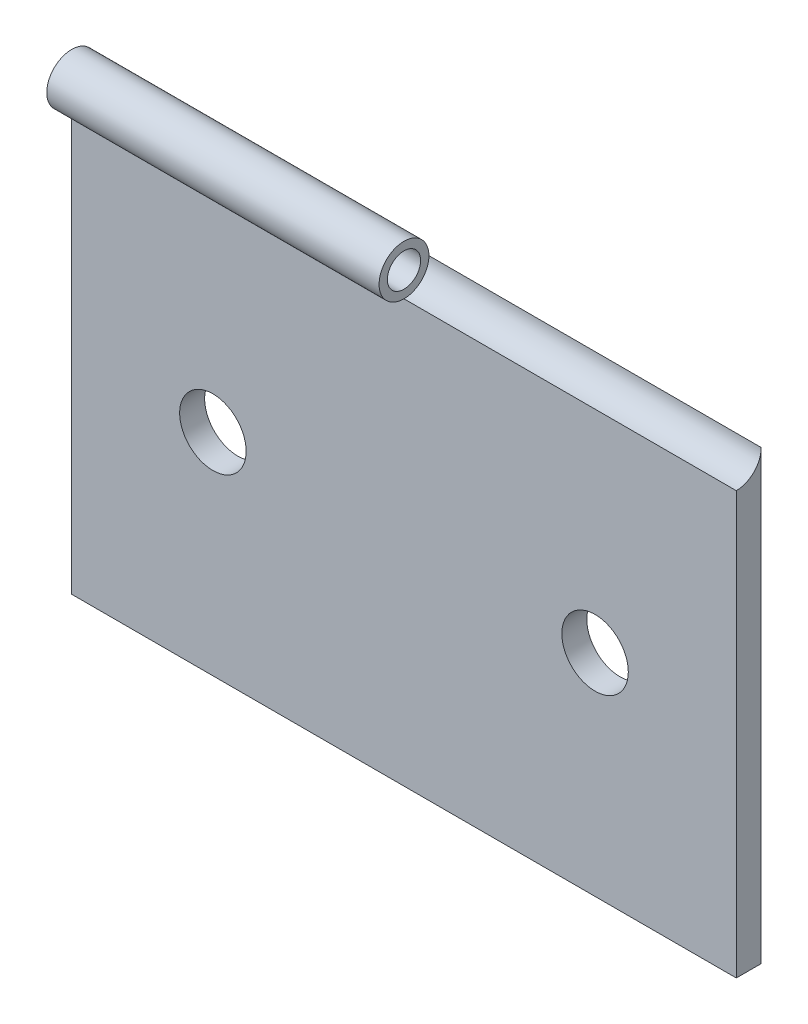
from build123d import *

# Parameters (mm, degrees)
CROQUIS1_R                   = 1
SALIENTE_EXTRUIR1_DEPTH      = 20
SALIENTE_EXTRUIR1_DEPTH_BACK = 20
CROQUIS3_R                   = 1.5
CORTAR_EXTRUIR1_DEPTH        = 20
CROQUIS4_R                   = 2
CORTAR_EXTRUIR2_DEPTH        = 1.5


with BuildPart() as part:
    # Croquis1 → Saliente-Extruir1 (new body, two sides)
    with BuildSketch(Plane(origin=(0, 0, 0), x_dir=(0, 0, -1), z_dir=(1, 0, 0))) as saliente_extruir1_sk:
        with BuildLine():
            Line((-0.75, -12.7), (0.75, -12.7))
            Line((0.75, -12.7), (0.75, 12.7))
            Line((0.75, 12.7), (0.75, 14.2))
            ThreePointArc((0.75, 14.2), (-1.810660172, 15.260660172), (-0.75, 12.7))
            Line((-0.75, 12.7), (-0.75, -12.7))
        make_face()
        with Locations((-0.75, 14.2)):
            Circle(CROQUIS1_R, mode=Mode.SUBTRACT)
    extrude(amount=SALIENTE_EXTRUIR1_DEPTH)
    extrude(saliente_extruir1_sk.sketch, amount=-SALIENTE_EXTRUIR1_DEPTH_BACK)

    # Croquis3 → Cortar-Extruir1 (cut)
    with BuildSketch(Plane(origin=(20, 0, 0), x_dir=(0, 0, -1), z_dir=(1, 0, 0))):
        with Locations((-0.75, 14.2)):
            Circle(CROQUIS3_R)
    extrude(amount=-CORTAR_EXTRUIR1_DEPTH, mode=Mode.SUBTRACT)

    # Croquis4 → Cortar-Extruir2 (cut)
    with BuildSketch(Plane.XY.offset(0.75)):
        with Locations((-11.5, 0)):
            Circle(CROQUIS4_R)
        with Locations((11.5, 0)):
            Circle(CROQUIS4_R)
    extrude(amount=-CORTAR_EXTRUIR2_DEPTH, mode=Mode.SUBTRACT)


solid = part.part
